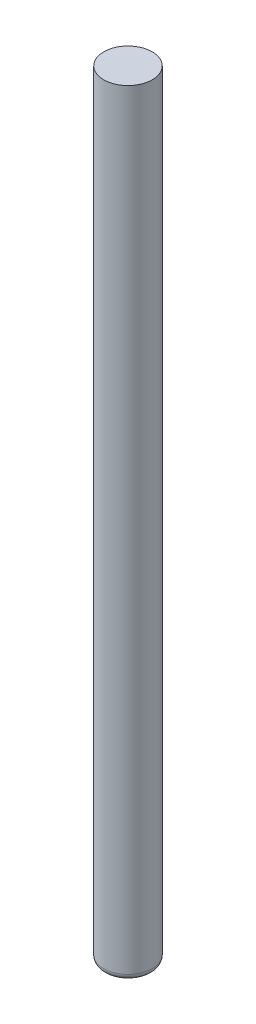
from build123d import *

# Parameters (mm, degrees)
SKETCH1_R           = 2
BOSS_EXTRUDE1_DEPTH = 64
FILLET1_R           = 0.5


with BuildPart() as part:
    # Sketch1 → Boss-Extrude1 (new body)
    with BuildSketch(Plane(origin=(0, 0, 0), x_dir=(1, 0, 0), z_dir=(0, 1, 0))):
        Circle(SKETCH1_R)
    extrude(amount=BOSS_EXTRUDE1_DEPTH)

    # Fillet1
    fillet1_edges = [part.edges().sort_by_distance(p)[0] for p in [
        (-2, 0, 0),
    ]]
    fillet(fillet1_edges, radius=FILLET1_R)


solid = part.part
